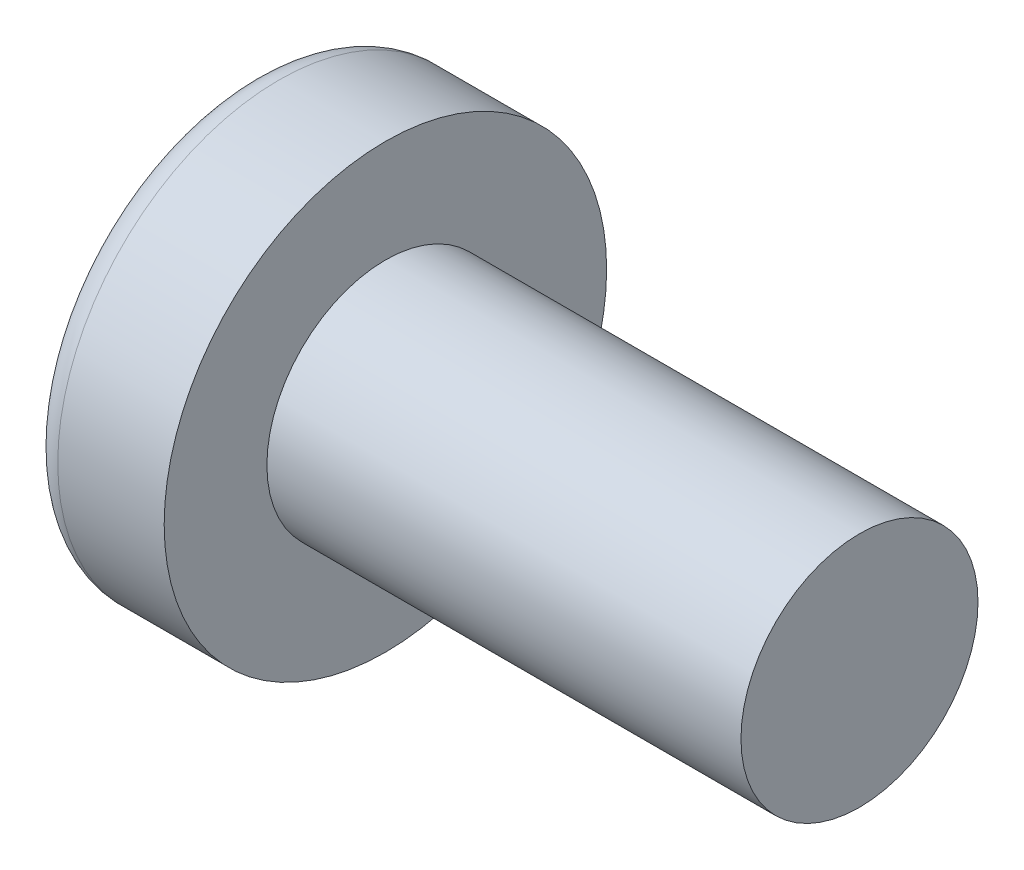
from build123d import *

# Parameters (mm, degrees)
SKETCH3_W         = 0.74
SKETCH3_H         = 2.9
SKETCH4_W         = 0.37
SKETCH4_H         = 0.37
CIRPATTERN1_COUNT = 2
CIRPATTERN1_ANGLE = 90


with BuildPart() as part:
    # BodySke → Base-Revolve (revolve)
    with BuildSketch(Plane.XY):
        with BuildLine():
            Line((2.4, 1.5), (2.4, 2.8))
            Line((2.4, 2.8), (1.053355856, 2.8))
            ThreePointArc((1.053355856, 2.8), (0.878072834, 2.754445324), (0.747150707, 2.629310345))
            ThreePointArc((0.747150707, 2.629310345), (0.190413403, 1.366702882), (0, 0))
            Line((0, 0), (8.4, 0))
            Line((8.4, 0), (8.4, 1.5))
            Line((8.4, 1.5), (2.4, 1.5))
        make_face()
    revolve(axis=Axis((-25.4, 0, 0), (1, 0, 0)))

    # Sketch3 → Cut-Loft1 section 0
    with BuildSketch(Plane(origin=(0, 0, 0), x_dir=(0, 0, -1), z_dir=(1, 0, 0))):
        Rectangle(SKETCH3_W, SKETCH3_H)
    # Sketch4 → Cut-Loft1 section 1
    with BuildSketch(Plane(origin=(1.76, 0, 0), x_dir=(0, 0, -1), z_dir=(1, 0, 0))):
        Rectangle(SKETCH4_W, SKETCH4_H)
    cut_loft1 = loft(mode=Mode.SUBTRACT)

    # CirPattern1: Cut-Loft1 ×2 about axis
    cirpattern1_axis = Axis((0, 0, 0), (1, 0, 0))
    for i in range(1, CIRPATTERN1_COUNT):
        add(cut_loft1.rotate(cirpattern1_axis, i * CIRPATTERN1_ANGLE / (CIRPATTERN1_COUNT - 1)), mode=Mode.SUBTRACT)


solid = part.part
